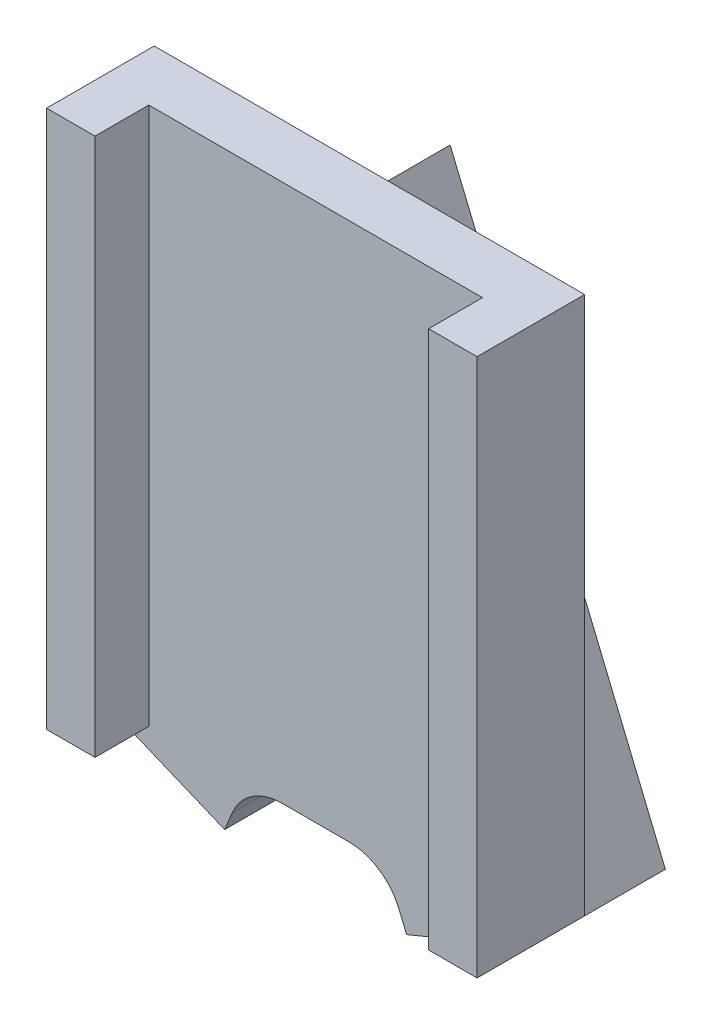
from build123d import *

# Parameters (mm, degrees)
SKETCH1_W                       = 8
SKETCH1_H                       = 10
BOSS_EXTRUDE1_DEPTH             = 2
SKETCH2_W                       = 6.2
SKETCH2_H                       = 10
CUT_EXTRUDE1_DEPTH              = 1
BOSS_EXTRUDE2_DEPTH             = 1.5
BOSS_EXTRUDE2_DEPTH_BACK        = 1
M1X0_2_TAPPED_HOLE1_D           = 0.8
M1X0_2_TAPPED_HOLE1_DEPTH       = 2.6
M1X0_2_TAPPED_HOLE1_CBORE_D     = 1
M1X0_2_TAPPED_HOLE1_CBORE_DEPTH = 2
M1X0_2_TAPPED_HOLE1_TIP         = 0.240344248
M1_CLEARANCE_HOLE1_D            = 1
M1_CLEARANCE_HOLE1_DEPTH        = 5
M1_CLEARANCE_HOLE1_TIP          = 0.30043031
SKETCH8_R                       = 0.4
CUT_EXTRUDE2_DEPTH              = 1.5
FILLET2_R                       = 1


with BuildPart() as part:
    # Sketch1 → Boss-Extrude1 (new body)
    with BuildSketch(Plane.XY):
        with Locations((4, -5)):
            Rectangle(SKETCH1_W, SKETCH1_H)
    extrude(amount=BOSS_EXTRUDE1_DEPTH)

    # Sketch2 → Cut-Extrude1 (cut)
    with BuildSketch(Plane.XY.offset(2)):
        with Locations((4, -5)):
            Rectangle(SKETCH2_W, SKETCH2_H)
    extrude(amount=-CUT_EXTRUDE1_DEPTH, mode=Mode.SUBTRACT)

    # Sketch3 → Boss-Extrude2 (add, two sides)
    with BuildSketch(Plane(origin=(0, 0, 0), x_dir=(-1, 0, 0), z_dir=(0, 0, -1))) as boss_extrude2_sk:
        Polygon((-8, -10), (-4, -0.343145751), (0, -10), (-2.309698831, -10.956708581), (-4, -6.875960575), (-5.690301169, -10.956708581), align=None)
    extrude(amount=BOSS_EXTRUDE2_DEPTH)
    extrude(boss_extrude2_sk.sketch, amount=-BOSS_EXTRUDE2_DEPTH_BACK)

    # M1x0.2 Tapped Hole1
    with Locations(Plane(origin=(-3.535533906, -8.535533906, 0), x_dir=(-0.923879533, 0.382683432, 0), z_dir=(-0.382683432, -0.923879533, 0))):
        with Locations((-5.115994416, 0.25)):
            CounterBoreHole(M1X0_2_TAPPED_HOLE1_D / 2, M1X0_2_TAPPED_HOLE1_CBORE_D / 2, M1X0_2_TAPPED_HOLE1_CBORE_DEPTH, depth=M1X0_2_TAPPED_HOLE1_DEPTH)
            with Locations((0, 0, -(M1X0_2_TAPPED_HOLE1_DEPTH + M1X0_2_TAPPED_HOLE1_TIP / 2))):  # 118° drill point
                Cone(0, M1X0_2_TAPPED_HOLE1_D / 2, M1X0_2_TAPPED_HOLE1_TIP, mode=Mode.SUBTRACT)

    # M1 Clearance Hole1
    with Locations(Plane(origin=(4.707106781, -11.363961031, 0), x_dir=(-0.923879533, -0.382683432, 0), z_dir=(0.382683432, -0.923879533, 0))):
        with Locations((-2.314201936, 0.25)):
            Hole(M1_CLEARANCE_HOLE1_D / 2, depth=M1_CLEARANCE_HOLE1_DEPTH)
            with Locations((0, 0, -(M1_CLEARANCE_HOLE1_DEPTH + M1_CLEARANCE_HOLE1_TIP / 2))):  # 118° drill point
                Cone(0, M1_CLEARANCE_HOLE1_D / 2, M1_CLEARANCE_HOLE1_TIP, mode=Mode.SUBTRACT)

    # Sketch8 → Cut-Extrude2 (cut)
    with BuildSketch(Plane(origin=(0, 0, -1.5), x_dir=(-1, 0, 0), z_dir=(0, 0, -1))):
        with Locations((-4, -7.3)):
            Circle(SKETCH8_R)
    extrude(amount=-CUT_EXTRUDE2_DEPTH, mode=Mode.SUBTRACT)

    # Fillet2
    fillet2_edges = [part.edges().sort_by_distance(p)[0] for p in [
        (2.705980501, -10, 0.5),
        (5.294019499, -10, 0.5),
    ]]
    fillet(fillet2_edges, radius=FILLET2_R)


solid = part.part
